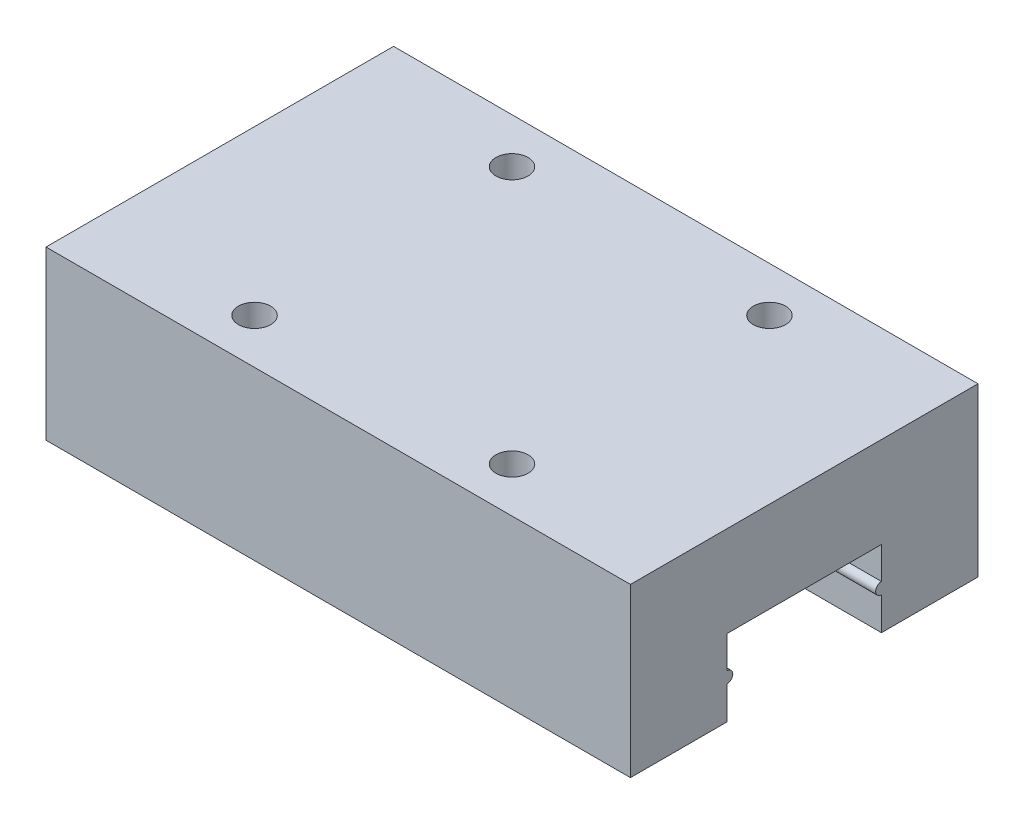
from build123d import *

# Parameters (mm, degrees)
BOSS_EXTRUDE1_DEPTH  = 45.4
LPATTERN1_COUNT      = 2
LPATTERN1_PITCH      = 20
LPATTERN1_COUNT_DIR2 = 2
LPATTERN1_PITCH_DIR2 = 20


with BuildPart() as part:
    # Sketch1 → Boss-Extrude1 (new body)
    with BuildSketch(Plane(origin=(0, 0, 0), x_dir=(0, 0, -1), z_dir=(1, 0, 0))):
        Polygon((19.5, 5.941454138), (19.5, 0), (27, 0), (27, 13), (0, 13), (0, 0), (7.5, 0), (7.5, 5.941454138), align=None)
        with BuildLine():
            Line((7.5, 3.45), (7.5, 2.55))
            ThreePointArc((7.5, 2.55), (7.95, 3), (7.5, 3.45))
        make_face()
        with BuildLine():
            ThreePointArc((19.5, 3.45), (19.05, 3), (19.5, 2.55))
            Line((19.5, 2.55), (19.5, 3.45))
        make_face()
    extrude(amount=BOSS_EXTRUDE1_DEPTH)

    # Sketch3 → M3x0.5 Tapped Hole1 (revolve, cut)
    with BuildSketch(Plane(origin=(12.7, 13, -23.5), x_dir=(0, 0, 1), z_dir=(1, 0, 0))):
        Polygon((0, 0), (0, 4.251075774), (1.25, 3.5), (1.25, 0), align=None)
    m3x0_5_tapped_hole1 = revolve(axis=Axis((12.7, 19.35, -23.5), (0, -1, 0)), mode=Mode.SUBTRACT)

    # LPattern1: M3x0.5 Tapped Hole1 2 × 2
    with Locations(*[(i * LPATTERN1_PITCH, 0, j * LPATTERN1_PITCH_DIR2) for i in range(LPATTERN1_COUNT) for j in range(LPATTERN1_COUNT_DIR2) if (i, j) != (0, 0)]):
        add(m3x0_5_tapped_hole1, mode=Mode.SUBTRACT)


solid = part.part
